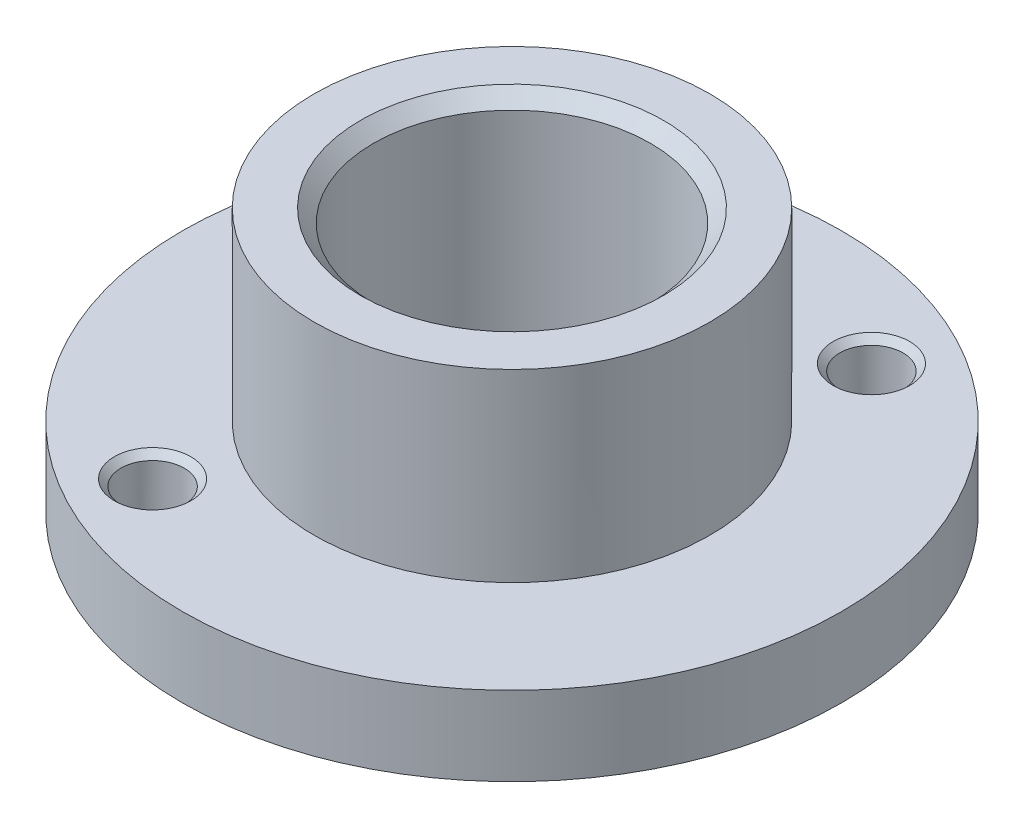
from build123d import *

# Parameters (mm, degrees)
SKETCH_1_R         = 7.5
SKETCH_1_R_2       = 5.25
EXTRUDE_1_DEPTH    = 10
SKETCH_2_R         = 12.5
SKETCH_2_R_2       = 7.5
EXTRUDE_2_DEPTH    = 3
HOLE_WIZARD_M2_1_D = 2.4
CHAMFER_1_SIZE     = 0.5
CHAMFER_2_SIZE     = 0.25


with BuildPart() as part:
    # 草图1 → 凸台-拉伸1 (new body)
    with BuildSketch(Plane(origin=(0, 0, 0), x_dir=(1, 0, 0), z_dir=(0, 1, 0))):
        Circle(SKETCH_1_R)
        Circle(SKETCH_1_R_2, mode=Mode.SUBTRACT)
    extrude(amount=EXTRUDE_1_DEPTH)

    # 草图2 → 凸台-拉伸2 (add)
    with BuildSketch(Plane.XZ):
        Circle(SKETCH_2_R)
        Circle(SKETCH_2_R_2, mode=Mode.SUBTRACT)
    extrude(amount=-EXTRUDE_2_DEPTH)

    # M2 间隙孔1 (through all)
    with Locations(Plane(origin=(-33.948689325, 3, -19.196001998), x_dir=(-0.49220518, 0, 0.870479213), z_dir=(0, 1, 0))):
        with Locations((-10.000000033, 38.999999994), (9.999999967, 38.999999994), (-3.3e-08, 28.999999994)):
            Hole(HOLE_WIZARD_M2_1_D / 2)

    # 倒角1
    chamfer_1_edges = [part.edges().sort_by_distance(p)[0] for p in [
        (-5.25, 10, 0),
    ]]
    chamfer(chamfer_1_edges, length=CHAMFER_1_SIZE)

    # 倒角2
    chamfer_2_edges = [part.edges().sort_by_distance(p)[0] for p in [
        (-9.295438348, 3, -3.877476747),
        (-5.512698019, 3, 9.749367187),
        (4.331405586, 3, -7.660217076),
    ]]
    chamfer(chamfer_2_edges, length=CHAMFER_2_SIZE)


solid = part.part
